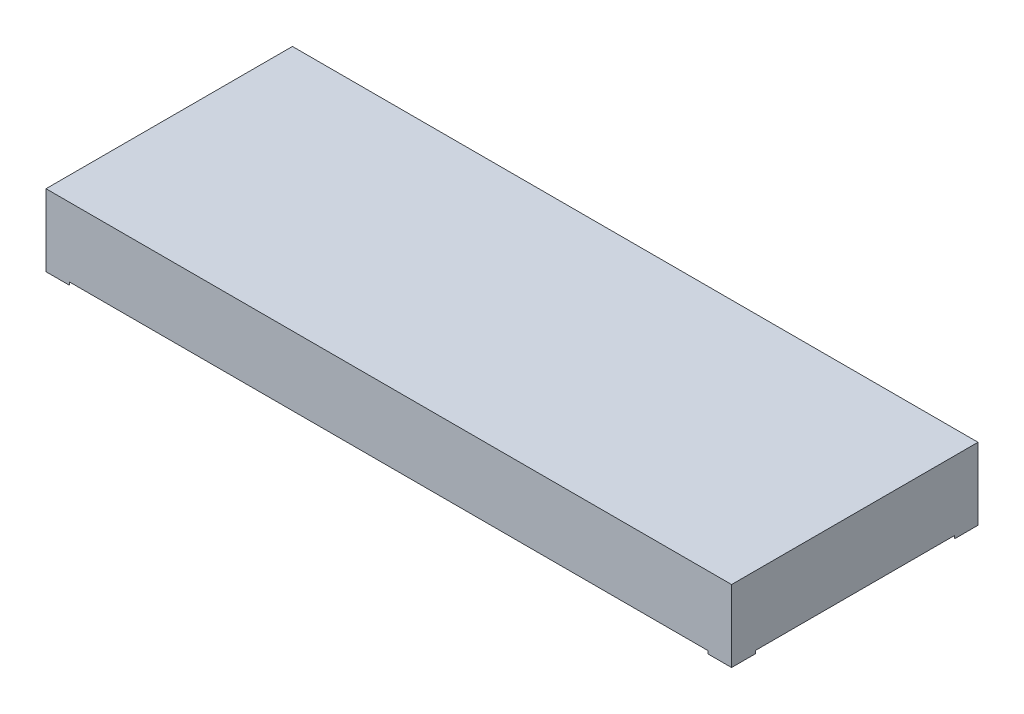
from build123d import *

# Parameters (mm, degrees)
SKETCH_1_W          = 71.5
SKETCH_1_H          = 25.7
EXTRUDE_1_DEPTH     = 7.5
CUT_EXTRUDE_1_DEPTH = 0.3


with BuildPart() as part:
    # 草图1 → 凸台-拉伸1 (new body)
    with BuildSketch(Plane(origin=(0, 0, 0), x_dir=(1, 0, 0), z_dir=(0, 1, 0))):
        with Locations((35.75, -12.85)):
            Rectangle(SKETCH_1_W, SKETCH_1_H)
    extrude(amount=EXTRUDE_1_DEPTH)

    # 草图2 → 切除-拉伸1 (cut)
    with BuildSketch(Plane.XZ):
        Polygon((69.025126266, 25.7), (2.474873734, 25.7), (0, 23.225126266), (0, 2.474873734), (2.474873734, 0), (69.025126266, 0), (71.5, 2.474873734), (71.5, 23.225126266), align=None)
    extrude(amount=-CUT_EXTRUDE_1_DEPTH, mode=Mode.SUBTRACT)


solid = part.part
